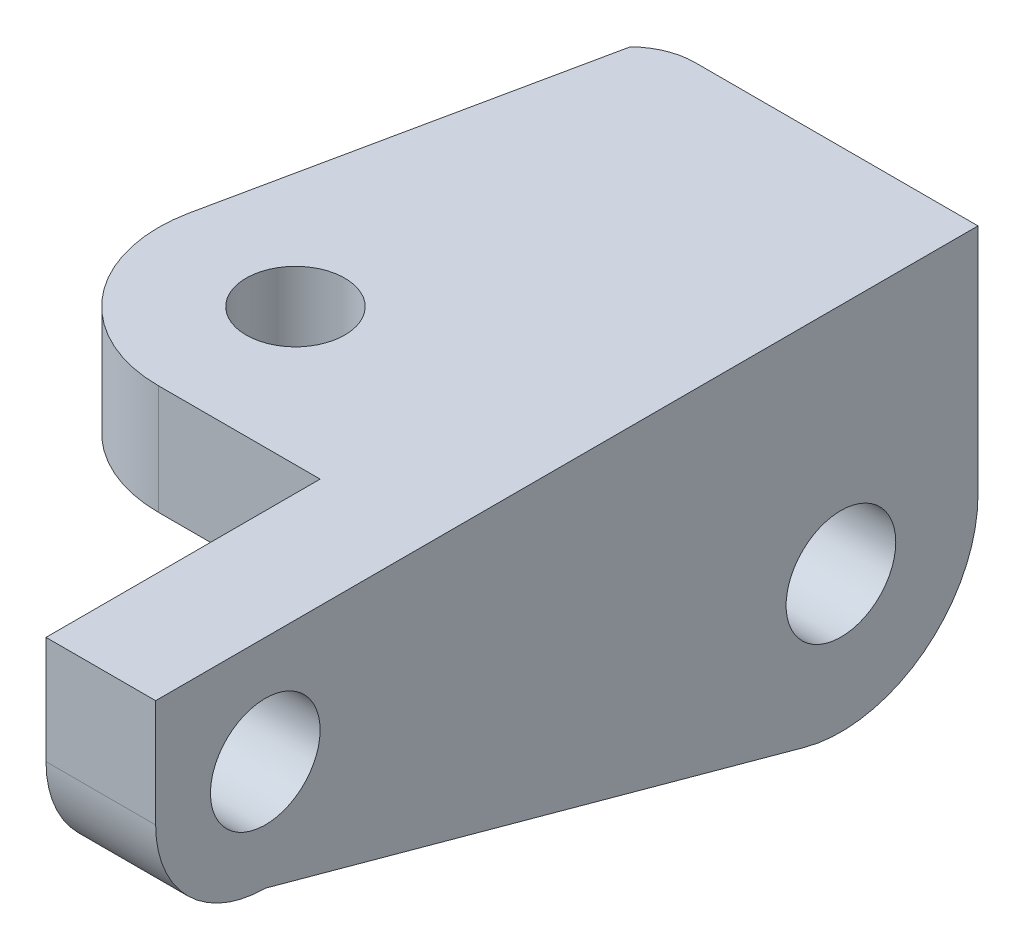
from build123d import *

# Parameters (mm, degrees)
SKETCH1_R           = 10
BOSS_EXTRUDE1_DEPTH = 20
SKETCH2_R           = 9
BOSS_EXTRUDE2_DEPTH = 20


with BuildPart() as part:
    # Sketch1 → Boss-Extrude1 (new body)
    with BuildSketch(Plane(origin=(0, 0, 0), x_dir=(0, 0, -1), z_dir=(1, 0, 0))):
        with BuildLine():
            Line((0, 0), (0, -19.63))
            ThreePointArc((0, -19.63), (5.857864376, -33.772135624), (20, -39.63))
            Line((20, -39.63), (118.39773122, -66.572445893))
            ThreePointArc((118.39773122, -66.572445893), (140.164815866, -62.335320368), (150, -42.46))
            Line((150, -42.46), (150, 0))
            Line((150, 0), (0, 0))
        make_face()
        with Locations((20, -19.63)):
            Circle(SKETCH1_R, mode=Mode.SUBTRACT)
        with Locations((125, -42.46)):
            Circle(SKETCH1_R, mode=Mode.SUBTRACT)
    extrude(amount=BOSS_EXTRUDE1_DEPTH)

    # Sketch2 → Boss-Extrude2 (add)
    with BuildSketch(Plane(origin=(0, 0, 0), x_dir=(1, 0, 0), z_dir=(0, 1, 0))):
        with BuildLine():
            Line((0, 150), (-31.593900405, 150))
            ThreePointArc((-31.593900405, 150), (-36.134562655, 149.107762436), (-40, 146.563731056))
            Line((-40, 146.563731056), (-53.965083284, 80.143899292))
            ThreePointArc((-53.965083284, 80.143899292), (-48.911304468, 59.245595573), (-29.5, 50))
            Line((-29.5, 50), (0, 50))
            Line((0, 50), (0, 150))
        make_face()
        with Locations((-29.5, 75)):
            Circle(SKETCH2_R, mode=Mode.SUBTRACT)
    extrude(amount=-BOSS_EXTRUDE2_DEPTH)


solid = part.part
